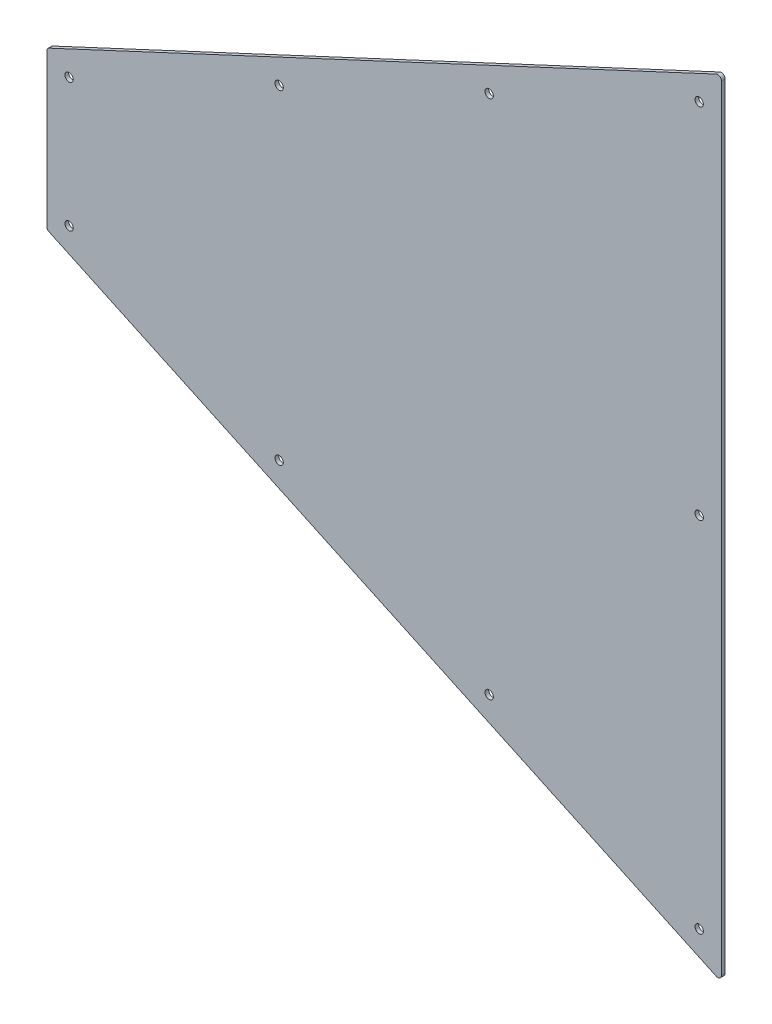
from build123d import *

# Parameters (mm, degrees)
ESQUISSE1_R        = 2.25
BOSS_EXTRU_1_DEPTH = 2


with BuildPart() as part:
    # Esquisse1 → Boss.-Extru.1 (new body)
    with BuildSketch(Plane(origin=(0, 0, 0), x_dir=(-1, 0, 0), z_dir=(0, 0, -1))):
        with BuildLine():
            Line((-3, -41.107892858), (-3, 41.107892858))
            ThreePointArc((-3, 41.107892858), (-3.313217108, 42.182492075), (-4.154763477, 42.920508432))
            Line((-4.154763477, 42.920508432), (-364.226714185, 210.824816534))
            ThreePointArc((-364.226714185, 210.824816534), (-366.146549925, 210.698983852), (-367.071950708, 209.01220096))
            Line((-367.071950708, 209.01220096), (-367.071950708, -209.01220096))
            ThreePointArc((-367.071950708, -209.01220096), (-366.146549925, -210.698983852), (-364.226714185, -210.824816534))
            Line((-364.226714185, -210.824816534), (-4.154763477, -42.920508432))
            ThreePointArc((-4.154763477, -42.920508432), (-3.313217108, -42.182492075), (-3, -41.107892858))
        make_face()
        with Locations(Location((-355.071950708, 0, 0), (0, 0, 180))):  # turned: the seam where the file's is
            Circle(ESQUISSE1_R, mode=Mode.SUBTRACT)
        with Locations(Location((-355.071950708, -193.315345189, 0), (0, 0, 180))):  # turned: the seam where the file's is
            Circle(ESQUISSE1_R, mode=Mode.SUBTRACT)
        with Locations(Location((-241.714633806, -140.455960209, 0), (0, 0, 180))):  # turned: the seam where the file's is
            Circle(ESQUISSE1_R, mode=Mode.SUBTRACT)
        with Locations(Location((-128.357316903, -87.59657523, 0), (0, 0, 180))):  # turned: the seam where the file's is
            Circle(ESQUISSE1_R, mode=Mode.SUBTRACT)
        with Locations(Location((-15, -34.73719025, 0), (0, 0, 180))):  # turned: the seam where the file's is
            Circle(ESQUISSE1_R, mode=Mode.SUBTRACT)
        with Locations(Location((-15, 34.73719025, 0), (0, 0, 180))):  # turned: the seam where the file's is
            Circle(ESQUISSE1_R, mode=Mode.SUBTRACT)
        with Locations(Location((-128.357316903, 87.59657523, 0), (0, 0, 180))):  # turned: the seam where the file's is
            Circle(ESQUISSE1_R, mode=Mode.SUBTRACT)
        with Locations(Location((-241.714633806, 140.455960209, 0), (0, 0, 180))):  # turned: the seam where the file's is
            Circle(ESQUISSE1_R, mode=Mode.SUBTRACT)
        with Locations(Location((-355.071950708, 193.315345189, 0), (0, 0, 180))):  # turned: the seam where the file's is
            Circle(ESQUISSE1_R, mode=Mode.SUBTRACT)
    extrude(amount=BOSS_EXTRU_1_DEPTH)


solid = part.part
